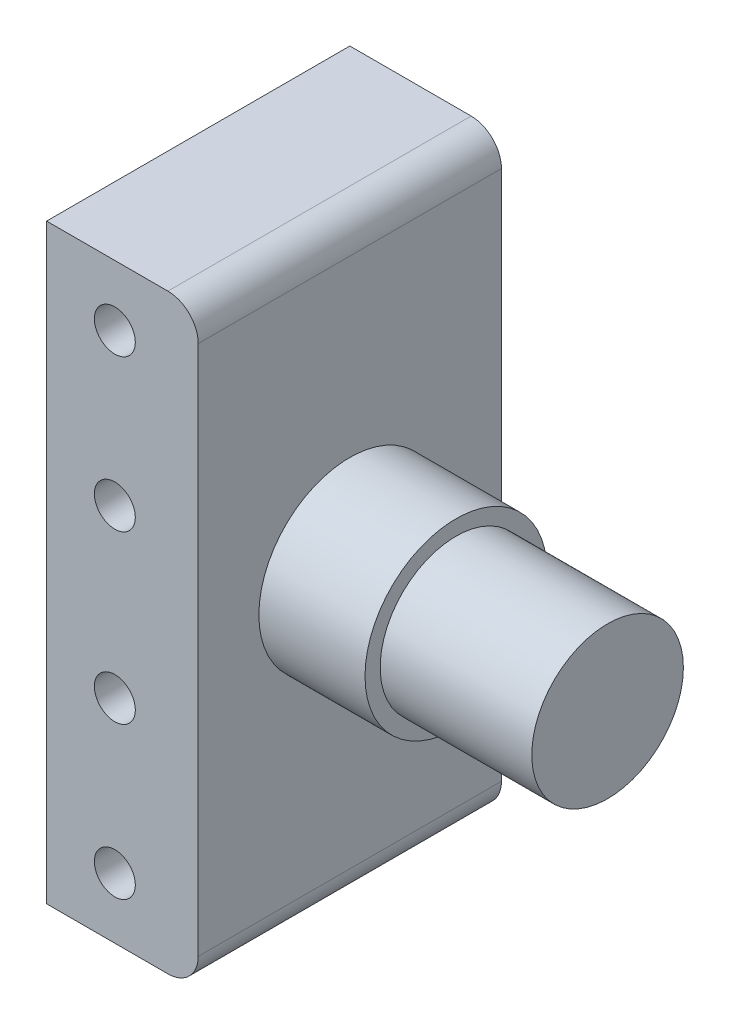
from build123d import *

# Parameters (mm, degrees)
BOSS_EXTRUDE1_DEPTH = 20
SKETCH2_R           = 1.35
CUT_EXTRUDE2_DEPTH  = 12
SKETCH3_R           = 5
BOSS_EXTRUDE2_DEPTH = 17
SKETCH4_R           = 6
BOSS_EXTRUDE3_DEPTH = 7


with BuildPart() as part:
    # Sketch1 → Boss-Extrude1 (new body)
    with BuildSketch(Plane.XY):
        with BuildLine():
            Line((-5, -19.5), (3, -19.5))
            ThreePointArc((3, -19.5), (4.414213562, -18.914213562), (5, -17.5))
            Line((5, -17.5), (5, 17.5))
            ThreePointArc((5, 17.5), (4.414213562, 18.914213562), (3, 19.5))
            Line((3, 19.5), (-5, 19.5))
            Line((-5, 19.5), (-5, -19.5))
        make_face()
    extrude(amount=BOSS_EXTRUDE1_DEPTH)

    # Sketch2 → Cut-Extrude2 (cut)
    with BuildSketch(Plane.XY.offset(20)):
        with Locations((-0.5, 15.5)):
            Circle(SKETCH2_R)
        with Locations((-0.5, 5.5)):
            Circle(SKETCH2_R)
        with Locations((-0.5, -15.5)):
            Circle(SKETCH2_R)
        with Locations((-0.5, -5.5)):
            Circle(SKETCH2_R)
    extrude(amount=-CUT_EXTRUDE2_DEPTH, mode=Mode.SUBTRACT)

    # Sketch3 → Boss-Extrude2 (add)
    with BuildSketch(Plane(origin=(5, 0, 0), x_dir=(0, 0, -1), z_dir=(1, 0, 0))):
        with Locations((-10, 0)):
            Circle(SKETCH3_R)
    extrude(amount=BOSS_EXTRUDE2_DEPTH)

    # Sketch4 → Boss-Extrude3 (add)
    with BuildSketch(Plane(origin=(5, 0, 0), x_dir=(0, 0, -1), z_dir=(1, 0, 0))):
        with Locations((-10, 0)):
            Circle(SKETCH4_R)
    extrude(amount=BOSS_EXTRUDE3_DEPTH)


solid = part.part
